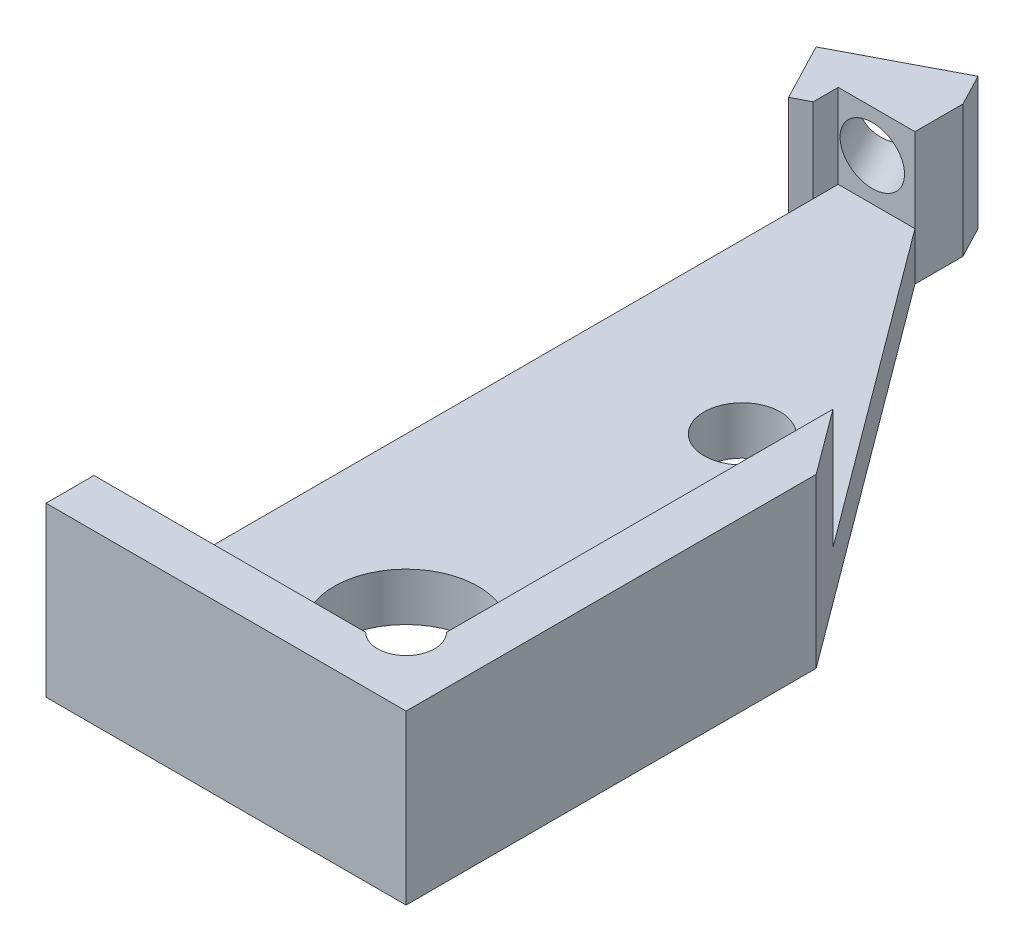
from build123d import *

# Parameters (mm, degrees)
SKETCH1_W                     = 7.5
SKETCH1_H                     = 17.5
BOSS_EXTRUDE1_DEPTH           = 3.5
SKETCH2_W                     = 5.5
SKETCH2_H                     = 15.5
CUT_EXTRUDE1_DEPTH            = 2.5
SKETCH3_R                     = 1.5
GRIN_HOLE_DEPTH               = 2
SKETCH6_R                     = 0.5953125
CORNER_DIVOT_DEPTH            = 2.5
SKETCH7_R                     = 0.79375
MAGNET_HOLES_DEPTH            = 2
BOSS_EXTRUDE2_DEPTH           = 3.5
SKETCH14_W                    = 5.965258944
SKETCH14_H                    = 5.132960456
SET_SCREW_EXTENSION_DEPTH     = 0.75
TAP_DRILL_FOR_0_80_TAP1_D     = 1.19126
TAP_DRILL_FOR_0_80_TAP1_DEPTH = 7.11
TAP_DRILL_FOR_0_80_TAP1_TIP   = 0.357890611
DIAGONAL_CUT_DEPTH            = 5
SKETCH16_W                    = 1
SKETCH16_H                    = 15.5
VERTICAL_CUT_DEPTH            = 3


with BuildPart() as part:
    # Sketch1 → Boss-Extrude1 (new body)
    with BuildSketch(Plane(origin=(0, 0, 0), x_dir=(1, 0, 0), z_dir=(0, 1, 0))):
        Rectangle(SKETCH1_W, SKETCH1_H)
    extrude(amount=BOSS_EXTRUDE1_DEPTH)

    # Sketch2 → Cut-Extrude1 (cut)
    with BuildSketch(Plane(origin=(0, 3.5, 0), x_dir=(1, 0, 0), z_dir=(0, 1, 0))):
        Rectangle(SKETCH2_W, SKETCH2_H)
    extrude(amount=-CUT_EXTRUDE1_DEPTH, mode=Mode.SUBTRACT)

    # Sketch3 → GRIN Hole (cut, through all)
    with BuildSketch(Plane(origin=(0, 1, 0), x_dir=(1, 0, 0), z_dir=(0, 1, 0))):
        with Locations((-0.25, -4.75)):
            Circle(SKETCH3_R)
    extrude(amount=-GRIN_HOLE_DEPTH, mode=Mode.SUBTRACT)

    # Sketch6 → Corner divot (cut)
    with BuildSketch(Plane(origin=(0, 3.5, 0), x_dir=(1, 0, 0), z_dir=(0, 1, 0))):
        with Locations((2.329050494, -7.329050494)):
            Circle(SKETCH6_R)
    extrude(amount=-CORNER_DIVOT_DEPTH, mode=Mode.SUBTRACT)

    # Sketch7 → Magnet Holes (cut, through all)
    with BuildSketch(Plane(origin=(0, 1, 0), x_dir=(1, 0, 0), z_dir=(0, 1, 0))):
        with Locations((-0.25, 2.25)):
            Circle(SKETCH7_R)
        with Locations((-2.125, -6.5)):
            Circle(SKETCH7_R)
        with Locations((1.625, -6.5)):
            Circle(SKETCH7_R)
    extrude(amount=-MAGNET_HOLES_DEPTH, mode=Mode.SUBTRACT)

    # Sketch9 → Boss-Extrude2 (add)
    with BuildSketch(Plane(origin=(0, 3.5, 0), x_dir=(1, 0, 0), z_dir=(0, 1, 0))):
        Polygon((-2.493978672, 9.405385289), (-4.710390263, 8.248873438), (-4.086258113, 7.05274758), (-3.457701518, 7.380725089), (-2.498403119, 7.881281923), (-1.869846523, 8.209259431), align=None)
    extrude(amount=-BOSS_EXTRUDE2_DEPTH)

    # Sketch14 → Set Screw Extension (cut)
    with BuildSketch(Plane(origin=(0, 3.5, 0), x_dir=(1, 0, 0), z_dir=(0, 1, 0))):
        with Locations((-2.75, 7.75)):
            Rectangle(SKETCH14_W, SKETCH14_H)
    extrude(amount=-SET_SCREW_EXTENSION_DEPTH, mode=Mode.SUBTRACT)

    # Tap Drill for #0-80 Tap1
    with Locations(Plane(origin=(-4.391140577, 0, -8.415456236), x_dir=(-0.886564636, 0, 0.46260474), z_dir=(-0.46260474, 0, -0.886564636))):
        with Locations((-0.889902526, 1.875)):
            Hole(TAP_DRILL_FOR_0_80_TAP1_D / 2, depth=TAP_DRILL_FOR_0_80_TAP1_DEPTH)
            with Locations((0, 0, -(TAP_DRILL_FOR_0_80_TAP1_DEPTH + TAP_DRILL_FOR_0_80_TAP1_TIP / 2))):  # 118° drill point
                Cone(0, TAP_DRILL_FOR_0_80_TAP1_D / 2, TAP_DRILL_FOR_0_80_TAP1_TIP, mode=Mode.SUBTRACT)

    # Sketch15 → Diagonal Cut (cut)
    with BuildSketch(Plane(origin=(0, 0, 0), x_dir=(1, 0, 0), z_dir=(0, 1, 0))):
        Polygon((-2.152002093, 9.313235547), (-2.152002093, 7.75), (3.75, -0.208562074), (3.75, 9.313235547), align=None)
    extrude(amount=DIAGONAL_CUT_DEPTH, mode=Mode.SUBTRACT)

    # Sketch16 → Vertical Cut (cut)
    with BuildSketch(Plane(origin=(0, 1, 0), x_dir=(1, 0, 0), z_dir=(0, 1, 0))):
        with Locations((-3.25, 0)):
            Rectangle(SKETCH16_W, SKETCH16_H)
    extrude(amount=VERTICAL_CUT_DEPTH, mode=Mode.SUBTRACT)


solid = part.part
